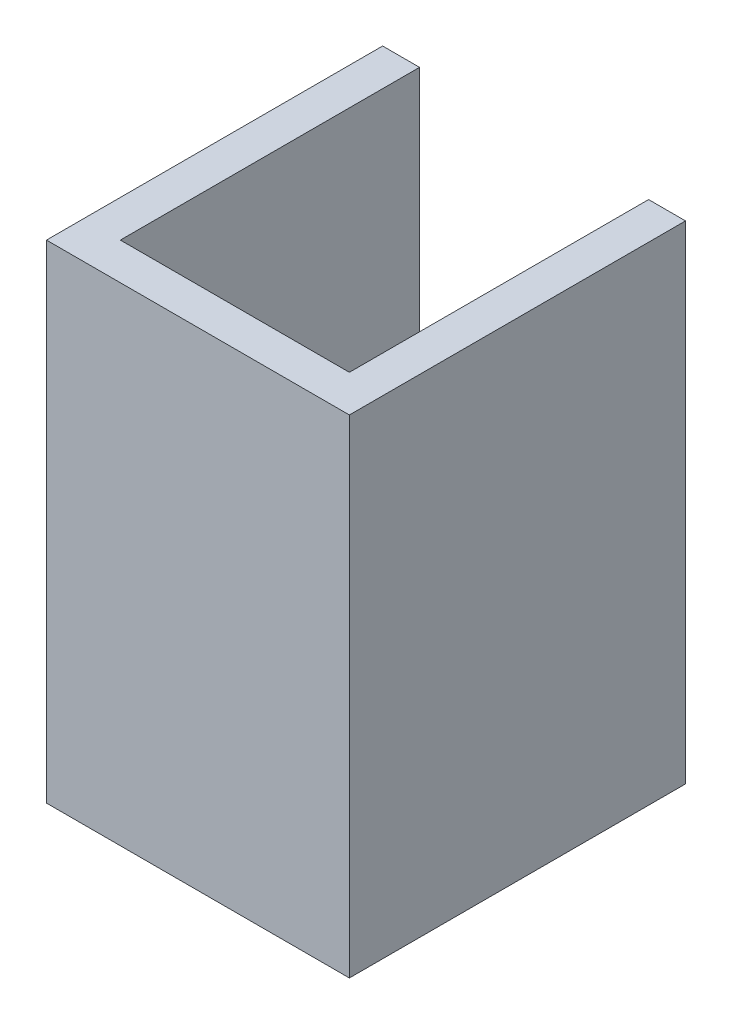
from build123d import *

# Parameters (mm, degrees)
EXTRUDE_1_DEPTH = 16.2
SKETCH_4_W      = 16.4
SKETCH_4_H      = 26.4
EXTRUDE_2_DEPTH = 2


with BuildPart() as part:
    # 草图1 → 凸台-拉伸1 (new body)
    with BuildSketch(Plane.XY):
        Polygon((-8.004506799, -8.377067037), (-8.004506799, 14.022932963), (-8.004506799, 16.022932963), (-10.004506799, 16.022932963), (-10.004506799, 14.022932963), (-10.004506799, -10.377067037), (6.395493201, -10.377067037), (6.395493201, 14.022932963), (6.395493201, 16.022932963), (4.395493201, 16.022932963), (4.395493201, 14.022932963), (4.395493201, -8.377067037), align=None)
    extrude(amount=EXTRUDE_1_DEPTH)

    # 草图4 → 凸台-拉伸2 (add)
    with BuildSketch(Plane.XY.offset(16.2)):
        with Locations((-1.804506799, 2.822932963)):
            Rectangle(SKETCH_4_W, SKETCH_4_H)
    extrude(amount=EXTRUDE_2_DEPTH)


solid = part.part
